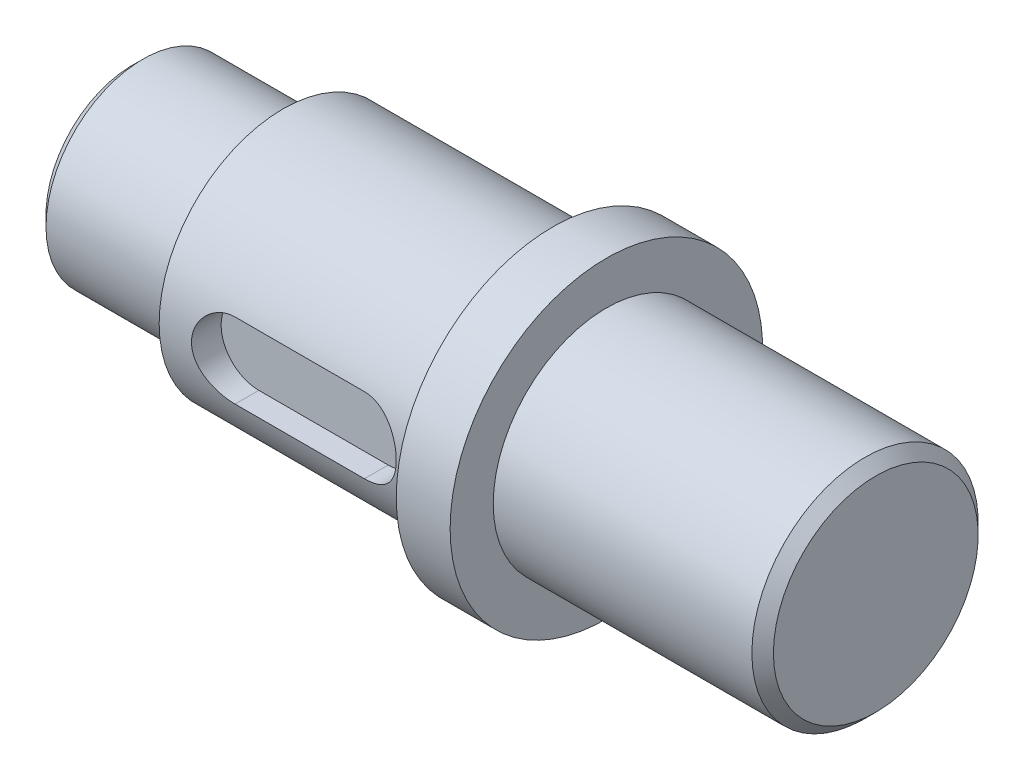
from build123d import *

# Parameters (mm, degrees)
CUT_EXTRUDE1_DEPTH = 5.5
CHAMFER2_SIZE      = 2


with BuildPart() as part:
    # Sketch1 → Revolve1 (revolve)
    with BuildSketch(Plane.XY):
        Polygon((0, 0), (0, 18), (28, 18), (28, 23), (78, 23), (78, 29), (88, 29), (88, 21), (138, 21), (138, 0), align=None)
    revolve(axis=Axis((0, 0, 0), (1, 0, 0)))

    # Sketch2 → Cut-Extrude1 (cut)
    with BuildSketch(Plane.XY.offset(23)):
        with BuildLine():
            Line((41, 7), (65, 7))
            ThreePointArc((65, 7), (72, 0), (65, -7))
            Line((65, -7), (41, -7))
            ThreePointArc((41, -7), (34, 0), (41, 7))
        make_face()
    extrude(amount=-CUT_EXTRUDE1_DEPTH, mode=Mode.SUBTRACT)

    # Chamfer2
    chamfer2_edges = [part.edges().sort_by_distance(p)[0] for p in [
        (0, -18, 0),
        (138, -21, 0),
    ]]
    chamfer(chamfer2_edges, length=CHAMFER2_SIZE)


solid = part.part
